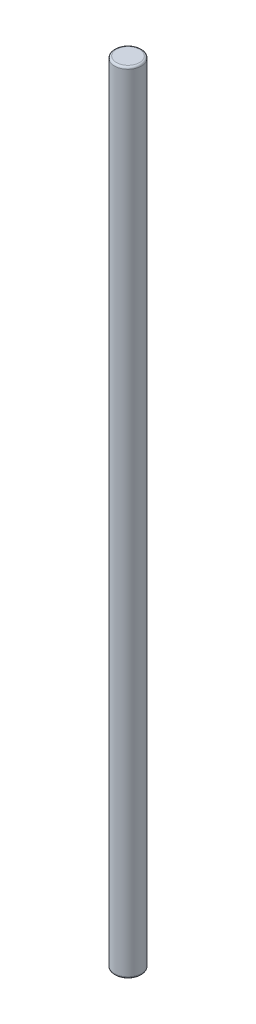
from build123d import *

# Parameters (mm, degrees)
SKETCH1_R           = 0.17145
FILLET1_R           = 0.0254
SKETCH3_W           = 2.124849291
SKETCH3_H           = 3.867225708
CUT_EXTRUDE1_DEPTH  = 1.27
SKETCH4_R           = 0.17145
BOSS_EXTRUDE1_DEPTH = 4.395936
FILLET2_R           = 0.0254


with BuildPart() as part:
    # Sweep1: sweep along a path in Sketch2
    with BuildLine(Plane.XY) as sweep1_path:
        Line((0, 0), (0, 6.582609755))
        ThreePointArc((0, 6.582609755), (0.019334599, 6.679811347), (0.074394878, 6.762214878))
        Line((0.074394878, 6.762214878), (0.433605122, 7.121425122))
        ThreePointArc((0.433605122, 7.121425122), (0.488665401, 7.203828653), (0.508, 7.301030245))
        Line((0.508, 7.301030245), (0.508, 8.41852666))
    # Sketch1 → Sweep1 (sweep)
    with BuildSketch(Plane(origin=(0, 0, 0), x_dir=(1, 0, 0), z_dir=(0, 1, 0))):
        Circle(SKETCH1_R)
    sweep(path=sweep1_path.line)

    # Fillet1
    fillet1_edges = [part.edges().sort_by_distance(p)[0] for p in [
        (-0.17145, 0, 0),
        (0.33655, 8.41852666, 0),
    ]]
    fillet(fillet1_edges, radius=FILLET1_R)

    # Sketch3 → Cut-Extrude1 (cut, symmetric)
    with BuildSketch(Plane.XY):
        with Locations((0.147757535, 7.545276716)):
            Rectangle(SKETCH3_W, SKETCH3_H)
    extrude(amount=CUT_EXTRUDE1_DEPTH, both=True, mode=Mode.SUBTRACT)

    # Sketch4 → Boss-Extrude1 (add)
    with BuildSketch(Plane(origin=(0, 5.611663862, 0), x_dir=(1, 0, 0), z_dir=(0, 1, 0))):
        Circle(SKETCH4_R)
    extrude(amount=BOSS_EXTRUDE1_DEPTH)

    # Fillet2
    fillet2_edges = [part.edges().sort_by_distance(p)[0] for p in [
        (-0.17145, 10.007599862, 0),
    ]]
    fillet(fillet2_edges, radius=FILLET2_R)


solid = part.part
